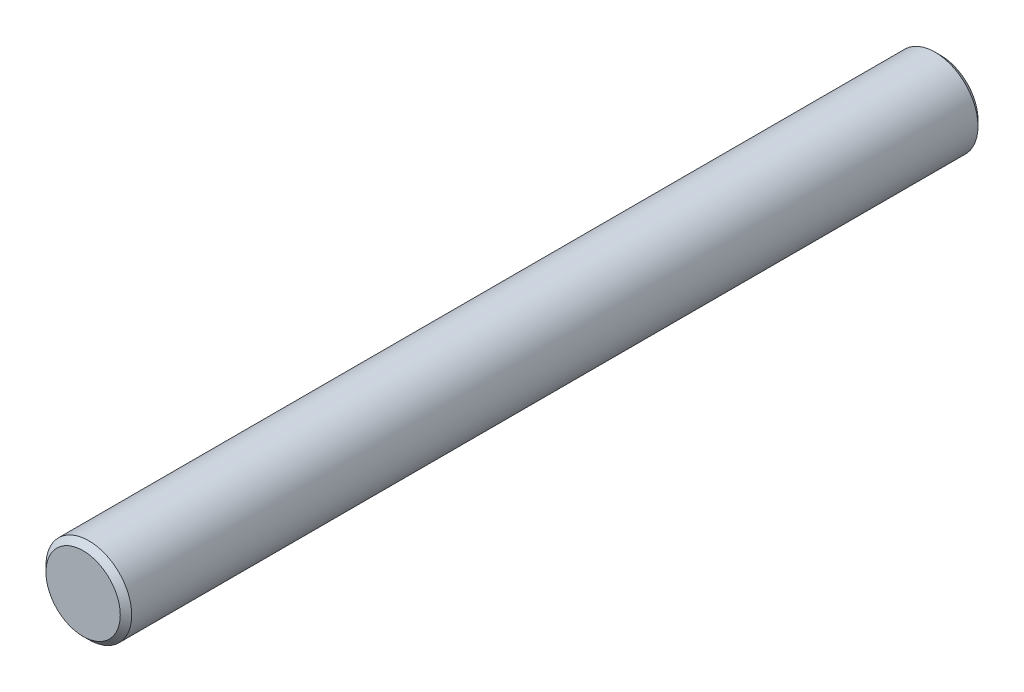
from build123d import *

# Parameters (mm, degrees)
SKETCH_1_R      = 1.5
EXTRUDE_1_DEPTH = 30
CHAMFER_1_SIZE  = 0.2


with BuildPart() as part:
    # 스케치1 → 보스-돌출1 (new body)
    with BuildSketch(Plane.XY):
        Circle(SKETCH_1_R)
    extrude(amount=EXTRUDE_1_DEPTH)

    # 모따기1
    chamfer_1_edges = [part.edges().sort_by_distance(p)[0] for p in [
        (-1.5, 0, 0),
        (-1.5, 0, 30),
    ]]
    chamfer(chamfer_1_edges, length=CHAMFER_1_SIZE)


solid = part.part
